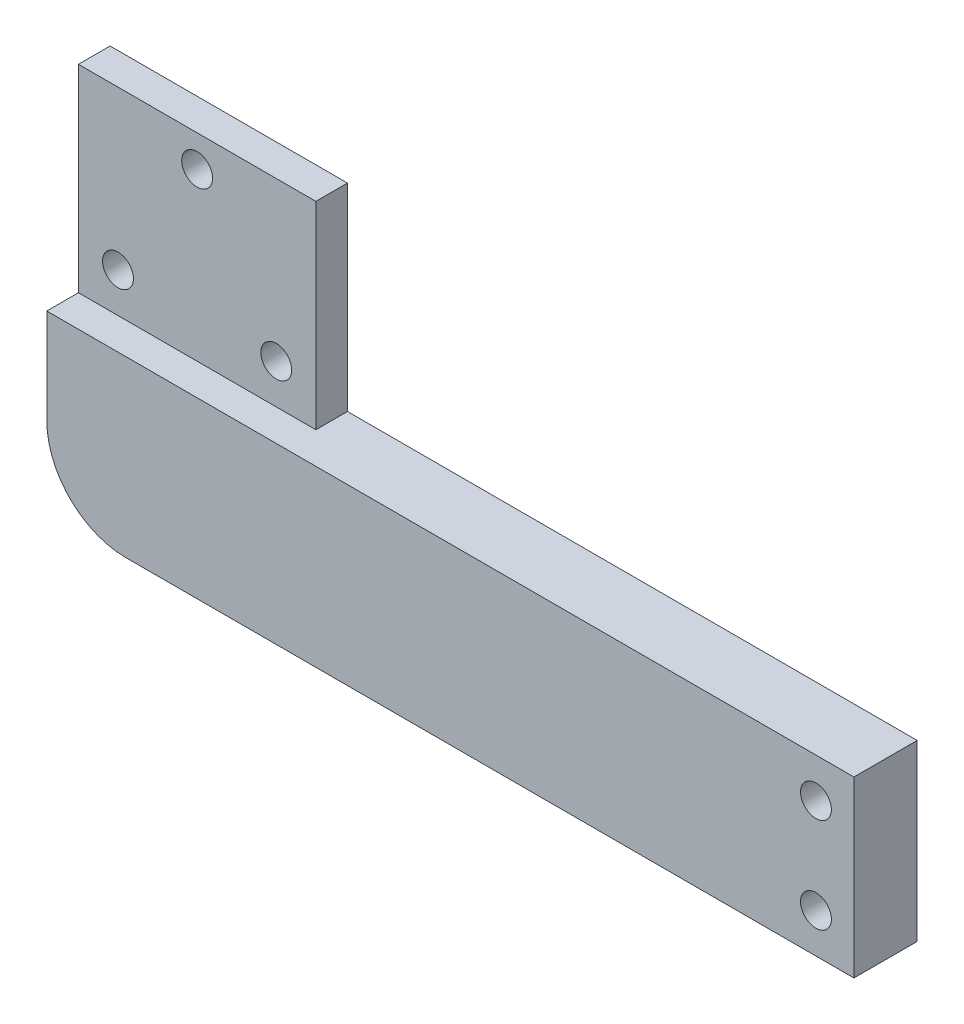
from build123d import *

# Parameters (mm, degrees)
SKETCH1_W                    = 102
SKETCH1_H                    = 22
EXTRUDE1_DEPTH               = 8
F_4_0_4_DIAMETER_HOLE1_D     = 3.9
F_4_0_4_DIAMETER_HOLE1_DEPTH = 15
SKETCH3_W                    = 30
SKETCH3_H                    = 25
EXTRUDE2_DEPTH               = 8
FILLET1_R                    = 10
F_4_0_4_DIAMETER_HOLE2_D     = 3.9
F_4_0_4_DIAMETER_HOLE2_DEPTH = 15
SKETCH5_W                    = 30
SKETCH5_H                    = 25
EXTRUDE3_DEPTH               = 4


with BuildPart() as part:
    # Sketch1 → Extrude1 (new body)
    with BuildSketch(Plane.XY):
        Rectangle(SKETCH1_W, SKETCH1_H)
    extrude(amount=EXTRUDE1_DEPTH)

    # Ø4.0 (4) Diameter Hole1
    with Locations(Plane(origin=(46.2, 6, 8), x_dir=(1, 0, 0), z_dir=(0, 0, 1))):
        with Locations((0, 0), (0, -12)):
            Hole(F_4_0_4_DIAMETER_HOLE1_D / 2, depth=F_4_0_4_DIAMETER_HOLE1_DEPTH)

    # Sketch3 → Extrude2 (add)
    with BuildSketch(Plane.XY):
        with Locations((-36, 23.5)):
            Rectangle(SKETCH3_W, SKETCH3_H)
    extrude(amount=EXTRUDE2_DEPTH)

    # Fillet1
    fillet1_edges = [part.edges().sort_by_distance(p)[0] for p in [
        (-51, -11, 4),
    ]]
    fillet(fillet1_edges, radius=FILLET1_R)

    # Ø4.0 (4) Diameter Hole2
    with Locations(Plane(origin=(-46, 16, 8), x_dir=(1, 0, 0), z_dir=(0, 0, 1))):
        with Locations((0, 0), (20, 0), (10, 16)):
            Hole(F_4_0_4_DIAMETER_HOLE2_D / 2, depth=F_4_0_4_DIAMETER_HOLE2_DEPTH)

    # Sketch5 → Extrude3 (cut)
    with BuildSketch(Plane.XY.offset(8)):
        with Locations((-36, 23.5)):
            Rectangle(SKETCH5_W, SKETCH5_H)
    extrude(amount=-EXTRUDE3_DEPTH, mode=Mode.SUBTRACT)


solid = part.part
